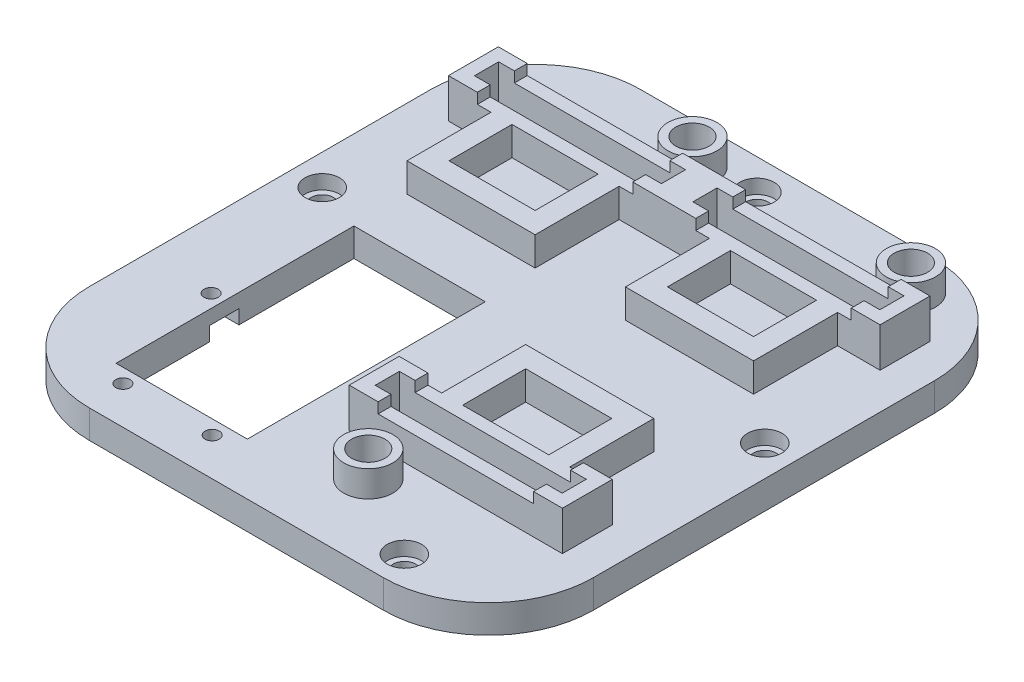
from build123d import *

# Parameters (mm, degrees)
W_TOP_DEPTH                  = 3.175
SKETCH3_W                    = 16.4
SKETCH3_H                    = 12
SKETCH3_W_2                  = 35.6
SKETCH3_H_2                  = 4.6
A_HOLDERS_DEPTH              = 5.5
A_CLAMP_DEPTH                = 2
SKETCH12_R                   = 1.35
SKETCH12_W                   = 25
SKETCH12_H                   = 45.3
A_HOLES_DEPTH                = 3.175
A_HOLES_START                = 1
A_HOLES_GUIDE_DEPTH          = 1.5
SKETCH15_R                   = 3.175
TENDON_HOLES_DEPTH           = 3.175
SKETCH16_R                   = 4.675
SKETCH16_R_2                 = 3.175
TUBE_SUPPORT_DEPTH           = 5
SKETCH19_R                   = 3.175
THICKNESS_COMPENSATION_DEPTH = 2.2
SKETCH18_R                   = 5
GEAR_PLACEMENTS_DEPTH        = 1.25
SKETCH20_R                   = 2.155
SCREW_HOLES_DEPTH            = 5.375
SKETCH21_R                   = 3.275
STANDOFF_HOLE_DEPTH          = 2.7


with BuildPart() as part:
    # Sketch1 → w_top (new body)
    with BuildSketch(Plane(origin=(0, 0, 0), x_dir=(1, 0, 0), z_dir=(0, 1, 0))):
        with BuildLine():
            Line((-48, -35), (-48, 30))
            ThreePointArc((-48, 30), (-42.142135624, 44.142135624), (-28, 50))
            Line((-28, 50), (28, 50))
            ThreePointArc((28, 50), (42.142135624, 44.142135624), (48, 30))
            Line((48, 30), (48, -35))
            ThreePointArc((48, -35), (42.142135624, -49.142135624), (28, -55))
            Line((28, -55), (-28, -55))
            ThreePointArc((-28, -55), (-42.142135624, -49.142135624), (-48, -35))
        make_face()
    extrude(amount=W_TOP_DEPTH)

    # Sketch3 → a_holders (add)
    with BuildSketch(Plane(origin=(0, 3.175, 0), x_dir=(1, 0, 0), z_dir=(0, 1, 0))):
        Polygon((0.5, -24.5), (0.5, -34), (41.1, -34), (41.1, -24.5), (33, -24.5), (33, -8.5), (8.6, -8.5), (8.6, -24.5), align=None)
        with Locations((20.8, -18.5)):
            Rectangle(SKETCH3_W, SKETCH3_H, mode=Mode.SUBTRACT)
        with Locations((20.8, -29.25)):
            Rectangle(SKETCH3_W_2, SKETCH3_H_2, mode=Mode.SUBTRACT)
        Polygon((8.6, 26.5), (-8.6, 26.5), (-8.6, 10.5), (-33, 10.5), (-33, 26.5), (-41.1, 26.5), (-41.1, 36), (41.1, 36), (41.1, 26.5), (33, 26.5), (33, 10.5), (8.6, 10.5), align=None)
        with Locations((20.8, 20.5)):
            Rectangle(SKETCH3_W, SKETCH3_H, mode=Mode.SUBTRACT)
        with Locations((-20.8, 20.5)):
            Rectangle(SKETCH3_W, SKETCH3_H, mode=Mode.SUBTRACT)
        with Locations((-20.8, 31.25)):
            Rectangle(SKETCH3_W_2, SKETCH3_H_2, mode=Mode.SUBTRACT)
        with Locations((20.8, 31.25)):
            Rectangle(SKETCH3_W_2, SKETCH3_H_2, mode=Mode.SUBTRACT)
    extrude(amount=A_HOLDERS_DEPTH)

    # Sketch14 → a_clamp (add)
    with BuildSketch(Plane(origin=(0, 8.675, 0), x_dir=(1, 0, 0), z_dir=(0, 1, 0))):
        Polygon((-35.6, 33.55), (-35.6, 36), (-41.1, 36), (-41.1, 26.5), (-35.6, 26.5), (-35.6, 28.95), (-38.6, 28.95), (-38.6, 33.55), align=None)
        Polygon((6, -24.5), (0.5, -24.5), (0.5, -34), (6, -34), (6, -31.55), (3, -31.55), (3, -26.95), (6, -26.95), align=None)
        Polygon((-3, 33.55), (-6, 33.55), (-6, 36), (6, 36), (6, 33.55), (3, 33.55), (3, 28.95), (6, 28.95), (6, 26.5), (-6, 26.5), (-6, 28.95), (-3, 28.95), align=None)
        Polygon((38.6, 33.55), (35.6, 33.55), (35.6, 36), (41.1, 36), (41.1, 26.5), (35.6, 26.5), (35.6, 28.95), (38.6, 28.95), align=None)
        Polygon((35.6, -26.95), (35.6, -24.5), (41.1, -24.5), (41.1, -34), (35.6, -34), (35.6, -31.55), (38.6, -31.55), (38.6, -26.95), align=None)
    extrude(amount=A_CLAMP_DEPTH)

    # Sketch12 → a_holes (cut)
    with BuildSketch(Plane(origin=(0, 3.175, 0), x_dir=(1, 0, 0), z_dir=(0, 1, 0))):
        with Locations((-28.8, -47.8)):
            Circle(SKETCH12_R)
        with Locations((-11.8, -47.8)):
            Circle(SKETCH12_R)
        with Locations((-35.3, -24.5)):
            Circle(SKETCH12_R)
        with Locations((-5.3, -24.5)):
            Circle(SKETCH12_R)
        with Locations((-20.3, -22.45)):
            Rectangle(SKETCH12_W, SKETCH12_H)
    extrude(amount=-A_HOLES_DEPTH, mode=Mode.SUBTRACT)

    # Sketch13 → a_holes guide (cut)
    with BuildSketch(Plane.XZ.offset(A_HOLES_START)):
        with BuildLine():
            Line((-31.6, 47.8), (-31.6, 45.1))
            Line((-31.6, 45.1), (-26, 45.1))
            Line((-26, 45.1), (-26, 47.8))
            ThreePointArc((-26, 47.8), (-28.8, 50.6), (-31.6, 47.8))
        make_face()
        with BuildLine():
            Line((-35.3, 27.3), (-32.8, 27.3))
            Line((-32.8, 27.3), (-32.8, 21.7))
            Line((-32.8, 21.7), (-35.3, 21.7))
            ThreePointArc((-35.3, 21.7), (-38.1, 24.5), (-35.3, 27.3))
        make_face()
        with BuildLine():
            Line((-7.8, 21.7), (-5.3, 21.7))
            ThreePointArc((-5.3, 21.7), (-2.5, 24.5), (-5.3, 27.3))
            Line((-5.3, 27.3), (-7.8, 27.3))
            Line((-7.8, 27.3), (-7.8, 21.7))
        make_face()
        with BuildLine():
            Line((-14.6, 45.1), (-14.6, 47.8))
            ThreePointArc((-14.6, 47.8), (-11.8, 50.6), (-9, 47.8))
            Line((-9, 47.8), (-9, 45.1))
            Line((-9, 45.1), (-14.6, 45.1))
        make_face()
    extrude(amount=-A_HOLES_GUIDE_DEPTH, mode=Mode.SUBTRACT)

    # Sketch15 → tendon holes (cut)
    with BuildSketch(Plane(origin=(0, 3.175, 0), x_dir=(1, 0, 0), z_dir=(0, 1, 0))):
        with Locations((-10.3, 42.17)):
            Circle(SKETCH15_R)
        with Locations((31.3, 42.17)):
            Circle(SKETCH15_R)
        with Locations((10.3, -40.17)):
            Circle(SKETCH15_R)
    extrude(amount=-TENDON_HOLES_DEPTH, mode=Mode.SUBTRACT)

    # Sketch16 → tube_support (add)
    with BuildSketch(Plane(origin=(0, 3.175, 0), x_dir=(1, 0, 0), z_dir=(0, 1, 0))):
        with Locations((-10.3, 42.17)):
            Circle(SKETCH16_R)
        with Locations((-10.3, 42.17)):
            Circle(SKETCH16_R_2, mode=Mode.SUBTRACT)
        with Locations((31.3, 42.17)):
            Circle(SKETCH16_R)
        with Locations((31.3, 42.17)):
            Circle(SKETCH16_R_2, mode=Mode.SUBTRACT)
        with Locations((10.3, -40.17)):
            Circle(SKETCH16_R)
        with Locations((10.3, -40.17)):
            Circle(SKETCH16_R_2, mode=Mode.SUBTRACT)
    extrude(amount=TUBE_SUPPORT_DEPTH)

    # Sketch19 → thickness compensation (add)
    with BuildSketch(Plane.XZ):
        with BuildLine():
            Line((-48, -30), (-48, 35))
            ThreePointArc((-48, 35), (-42.142135624, 49.142135624), (-28, 55))
            Line((-28, 55), (28, 55))
            ThreePointArc((28, 55), (42.142135624, 49.142135624), (48, 35))
            Line((48, 35), (48, -30))
            ThreePointArc((48, -30), (42.142135624, -44.142135624), (28, -50))
            Line((28, -50), (-28, -50))
            ThreePointArc((-28, -50), (-42.142135624, -44.142135624), (-48, -30))
        make_face()
        with Locations((10.3, 40.17)):
            Circle(SKETCH19_R, mode=Mode.SUBTRACT)
        with Locations((-10.3, -42.17)):
            Circle(SKETCH19_R, mode=Mode.SUBTRACT)
        with Locations((31.3, -42.17)):
            Circle(SKETCH19_R, mode=Mode.SUBTRACT)
        with BuildLine():
            Line((-32.8, -0.2), (-7.8, -0.2))
            Line((-7.8, -0.2), (-7.8, 21.7))
            Line((-7.8, 21.7), (-5.3, 21.7))
            ThreePointArc((-5.3, 21.7), (-2.5, 24.5), (-5.3, 27.3))
            Line((-5.3, 27.3), (-7.8, 27.3))
            Line((-7.8, 27.3), (-7.8, 45.1))
            Line((-7.8, 45.1), (-9, 45.1))
            Line((-9, 45.1), (-9, 47.8))
            ThreePointArc((-9, 47.8), (-11.8, 50.6), (-14.6, 47.8))
            Line((-14.6, 47.8), (-14.6, 45.1))
            Line((-14.6, 45.1), (-26, 45.1))
            Line((-26, 45.1), (-26, 47.8))
            ThreePointArc((-26, 47.8), (-28.8, 50.6), (-31.6, 47.8))
            Line((-31.6, 47.8), (-31.6, 45.1))
            Line((-31.6, 45.1), (-32.8, 45.1))
            Line((-32.8, 45.1), (-32.8, 27.3))
            Line((-32.8, 27.3), (-35.3, 27.3))
            ThreePointArc((-35.3, 27.3), (-38.1, 24.5), (-35.3, 21.7))
            Line((-35.3, 21.7), (-32.8, 21.7))
            Line((-32.8, 21.7), (-32.8, -0.2))
        make_face(mode=Mode.SUBTRACT)
    extrude(amount=THICKNESS_COMPENSATION_DEPTH)

    # Sketch18 → gear placements (cut)
    with BuildSketch(Plane.XZ.offset(2.2)):
        with Locations((-3.329437252, -4.970562748)):
            Circle(SKETCH18_R)
        with Locations((10.3, 14.783890932)):
            Circle(SKETCH18_R)
        with Locations((32.995036048, 22.59)):
            Circle(SKETCH18_R)
        with Locations((10.5, -24.585522991)):
            Circle(SKETCH18_R)
    extrude(amount=-GEAR_PLACEMENTS_DEPTH, mode=Mode.SUBTRACT)

    # Sketch20 → screw holes (cut)
    with BuildSketch(Plane.XZ.offset(2.2)):
        with Locations((-42.142135624, -3.5)):
            Circle(SKETCH20_R)
        with Locations((0, -44.142135624)):
            Circle(SKETCH20_R)
        with Locations((42.142135624, -3.5)):
            Circle(SKETCH20_R)
        with Locations((26.142135624, 49.142135624)):
            Circle(SKETCH20_R)
    extrude(amount=-SCREW_HOLES_DEPTH, mode=Mode.SUBTRACT)

    # Sketch21 → standoff hole (cut)
    with BuildSketch(Plane(origin=(0, 3.175, 0), x_dir=(1, 0, 0), z_dir=(0, 1, 0))):
        with Locations((-42.142135624, 3.5)):
            Circle(SKETCH21_R)
        with Locations((42.142135624, 3.5)):
            Circle(SKETCH21_R)
        with Locations((0, 44.142135624)):
            Circle(SKETCH21_R)
        with Locations((26.142135624, -49.142135624)):
            Circle(SKETCH21_R)
    extrude(amount=-STANDOFF_HOLE_DEPTH, mode=Mode.SUBTRACT)


solid = part.part
